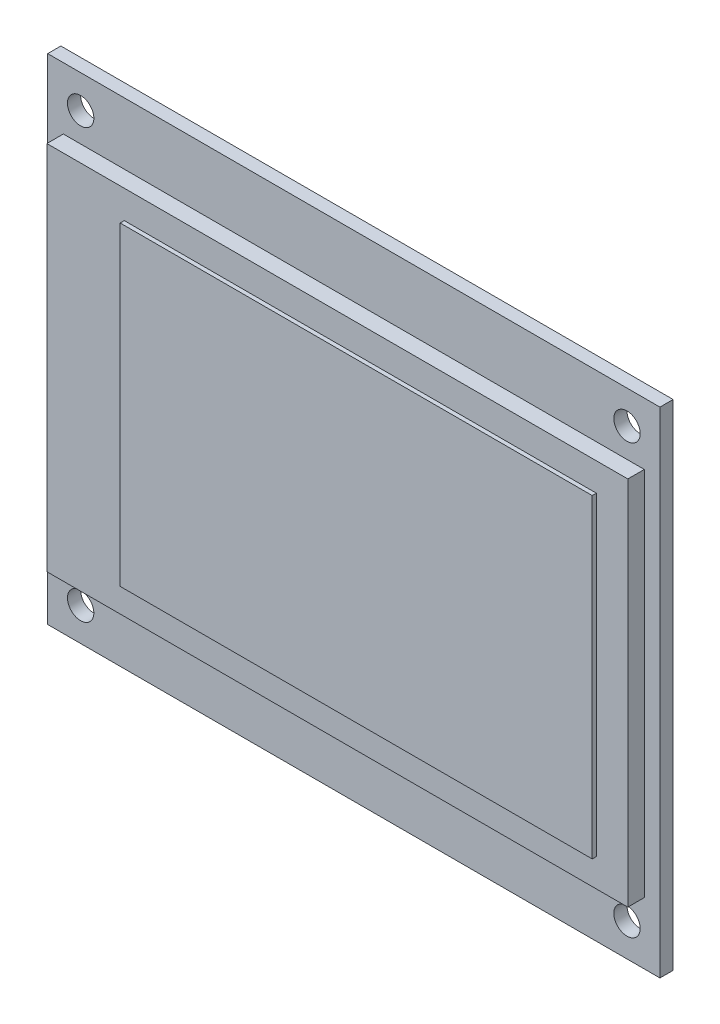
from build123d import *

# Parameters (mm, degrees)
SKETCH1_W                      = 74.3
SKETCH1_H                      = 60
BOSS_EXTRUDE1_DEPTH            = 1.6
SKETCH2_W                      = 1.9
SKETCH2_H                      = 15
CUT_EXTRUDE1_DEPTH             = 2.6
F_3_2_3_2_DIAMETER_HOLE1_D     = 3.2
F_3_2_3_2_DIAMETER_HOLE1_DEPTH = 60
F_3_2_3_2_DIAMETER_HOLE1_TIP   = 0.96137699
SKETCH6_W                      = 70.5
SKETCH6_H                      = 45
BOSS_EXTRUDE2_DEPTH            = 2
SKETCH7_W                      = 57.288
SKETCH7_H                      = 38.192
BOSS_EXTRUDE3_DEPTH            = 0.5


with BuildPart() as part:
    # Sketch1 → Boss-Extrude1 (new body)
    with BuildSketch(Plane.XY):
        with Locations((37.15, 30)):
            Rectangle(SKETCH1_W, SKETCH1_H)
    extrude(amount=BOSS_EXTRUDE1_DEPTH)

    # Sketch2 → Cut-Extrude1 (cut, through all)
    with BuildSketch(Plane.XY.offset(1.6)):
        with Locations((0.95, 15)):
            Rectangle(SKETCH2_W, SKETCH2_H)
    extrude(amount=-CUT_EXTRUDE1_DEPTH, mode=Mode.SUBTRACT)

    # Ø3.2 (3.2) Diameter Hole1
    with Locations(Plane.XY.offset(1.6)):
        with Locations((4, 56), (70.3, 56), (70.3, 4), (4, 4)):
            Hole(F_3_2_3_2_DIAMETER_HOLE1_D / 2, depth=F_3_2_3_2_DIAMETER_HOLE1_DEPTH)
            with Locations((0, 0, -(F_3_2_3_2_DIAMETER_HOLE1_DEPTH + F_3_2_3_2_DIAMETER_HOLE1_TIP / 2))):  # 118° drill point
                Cone(0, F_3_2_3_2_DIAMETER_HOLE1_D / 2, F_3_2_3_2_DIAMETER_HOLE1_TIP, mode=Mode.SUBTRACT)

    # Sketch6 → Boss-Extrude2 (add)
    with BuildSketch(Plane.XY.offset(1.6)):
        with Locations((37.15, 30)):
            Rectangle(SKETCH6_W, SKETCH6_H)
    extrude(amount=BOSS_EXTRUDE2_DEPTH)

    # Sketch7 → Boss-Extrude3 (add)
    with BuildSketch(Plane.XY.offset(3.6)):
        with Locations((39.936, 30)):
            Rectangle(SKETCH7_W, SKETCH7_H)
    extrude(amount=BOSS_EXTRUDE3_DEPTH)


solid = part.part
